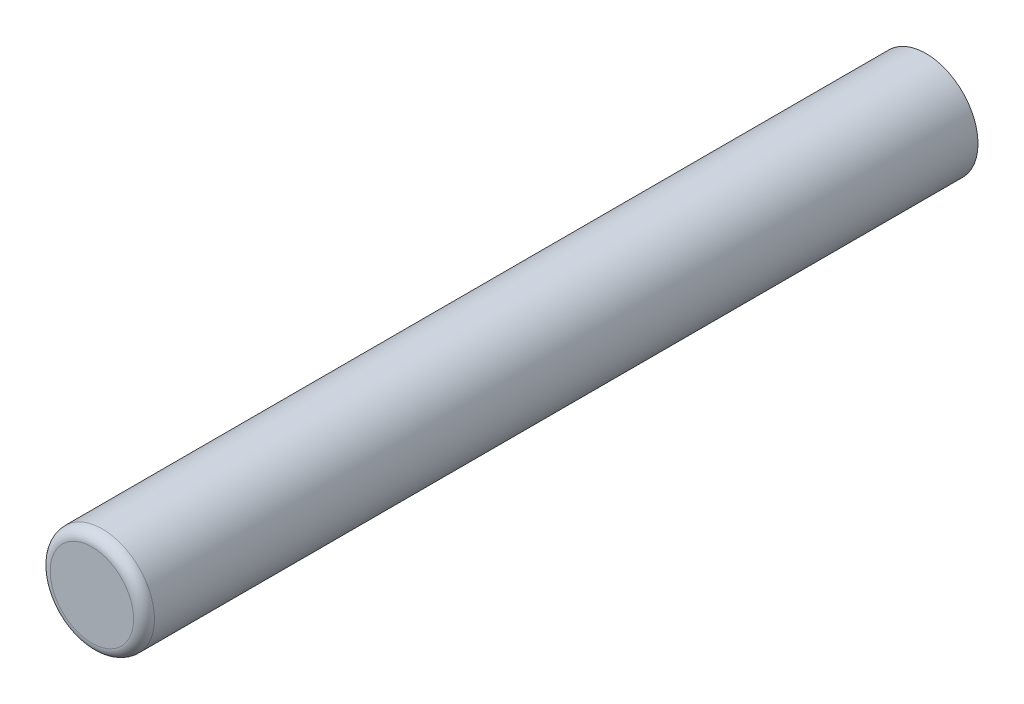
from build123d import *

# Parameters (mm, degrees)
SKETCH1_R                 = 6.35
BOSS_EXTRUDE1_DEPTH       = 101.6
M5X0_8_TAPPED_HOLE1_D     = 4.2
M5X0_8_TAPPED_HOLE1_DEPTH = 25.4
M5X0_8_TAPPED_HOLE1_TIP   = 1.2618073
FILLET1_R                 = 1.27


with BuildPart() as part:
    # Sketch1 → Boss-Extrude1 (new body)
    with BuildSketch(Plane.XY):
        Circle(SKETCH1_R)
    extrude(amount=BOSS_EXTRUDE1_DEPTH)

    # M5x0.8 Tapped Hole1
    with Locations(Plane(origin=(0, 0, 0), x_dir=(-1, 0, 0), z_dir=(0, 0, -1))):
        with Locations((0, 0)):
            Hole(M5X0_8_TAPPED_HOLE1_D / 2, depth=M5X0_8_TAPPED_HOLE1_DEPTH)
            with Locations((0, 0, -(M5X0_8_TAPPED_HOLE1_DEPTH + M5X0_8_TAPPED_HOLE1_TIP / 2))):  # 118° drill point
                Cone(0, M5X0_8_TAPPED_HOLE1_D / 2, M5X0_8_TAPPED_HOLE1_TIP, mode=Mode.SUBTRACT)

    # Fillet1
    fillet1_edges = [part.edges().sort_by_distance(p)[0] for p in [
        (-6.35, 0, 101.6),
    ]]
    fillet(fillet1_edges, radius=FILLET1_R)


solid = part.part
